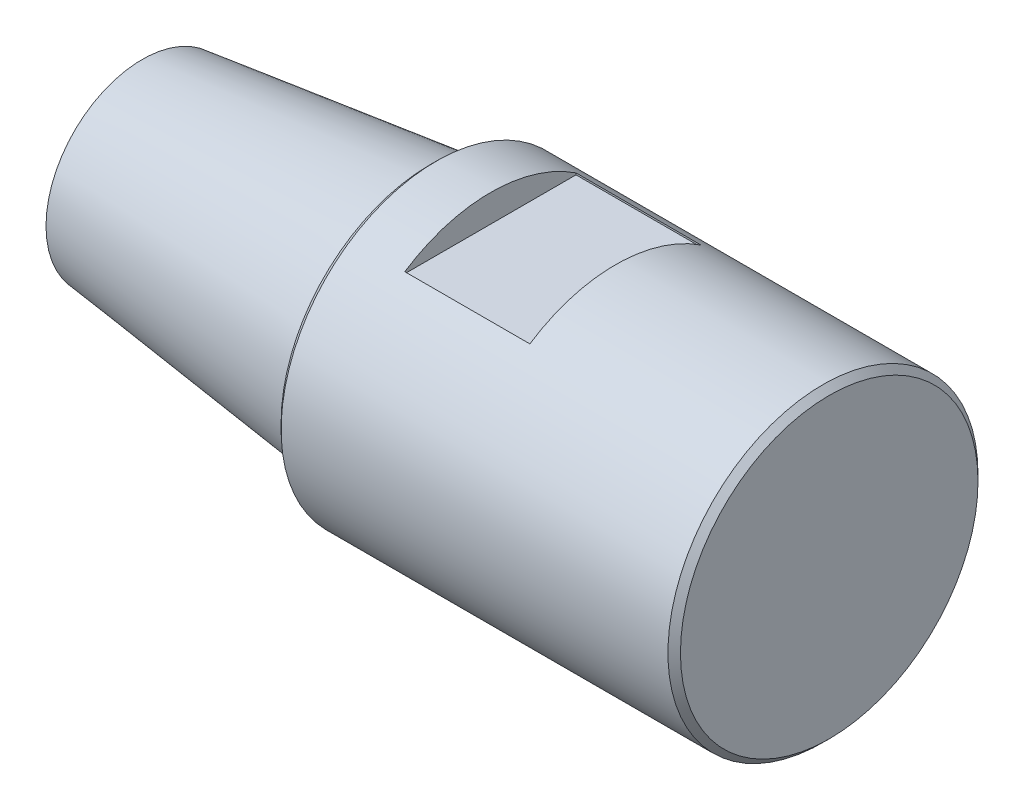
from build123d import *

# Parameters (mm, degrees)
SKIZZE2_R                       = 24.795
AUFSATZ_LINEAR_AUSTRAGEN1_DEPTH = 63.87
SKIZZE8_W                       = 20
SKIZZE8_H                       = 27.38
SCHNITT_LINEAR_AUSTRAGEN1_DEPTH = 4.4
KREISMUSTER1_COUNT              = 2
FASE1_SIZE                      = 1


with BuildPart() as part:
    # Skizze1 → Rotation1 (revolve)
    with BuildSketch(Plane(origin=(0, 0, 0), x_dir=(1, 0, 0), z_dir=(0, 1, 0)), mode=Mode.PRIVATE) as rotation1_sk:
        Polygon((-46, 0), (-46, 15.4), (0, 20.905), (0, 0), align=None)
    revolve(rotation1_sk.sketch.rotate(Axis((-46, 0, 0), (1, 0, 0)), 180), axis=Axis((-46, 0, 0), (1, 0, 0)))  # turned: the seam where the file's is

    # Skizze2 → Aufsatz-Linear austragen1 (add)
    with BuildSketch(Plane(origin=(0, 0, 0), x_dir=(0, 0, -1), z_dir=(1, 0, 0))):
        Circle(SKIZZE2_R)
    extrude(amount=AUFSATZ_LINEAR_AUSTRAGEN1_DEPTH)

    # Skizze8 → Schnitt-Linear austragen1 (cut)
    with BuildSketch(Plane(origin=(0, 24.795, 0), x_dir=(1, 0, 0), z_dir=(0, 1, 0))):
        with Locations((19.68, 0)):
            Rectangle(SKIZZE8_W, SKIZZE8_H)
    schnitt_linear_austragen1 = extrude(amount=-SCHNITT_LINEAR_AUSTRAGEN1_DEPTH, mode=Mode.SUBTRACT)

    # Kreismuster1: Schnitt-Linear austragen1 ×2 about axis
    kreismuster1_axis = Axis((0, 0, 0), (1, 0, 0))
    for i in range(1, KREISMUSTER1_COUNT):
        add(schnitt_linear_austragen1.rotate(kreismuster1_axis, i * 360 / KREISMUSTER1_COUNT), mode=Mode.SUBTRACT)

    # Fase1
    fase1_edges = [part.edges().sort_by_distance(p)[0] for p in [
        (0, 0, 24.795),
        (63.87, 0, 24.795),
    ]]
    chamfer(fase1_edges, length=FASE1_SIZE)


solid = part.part
